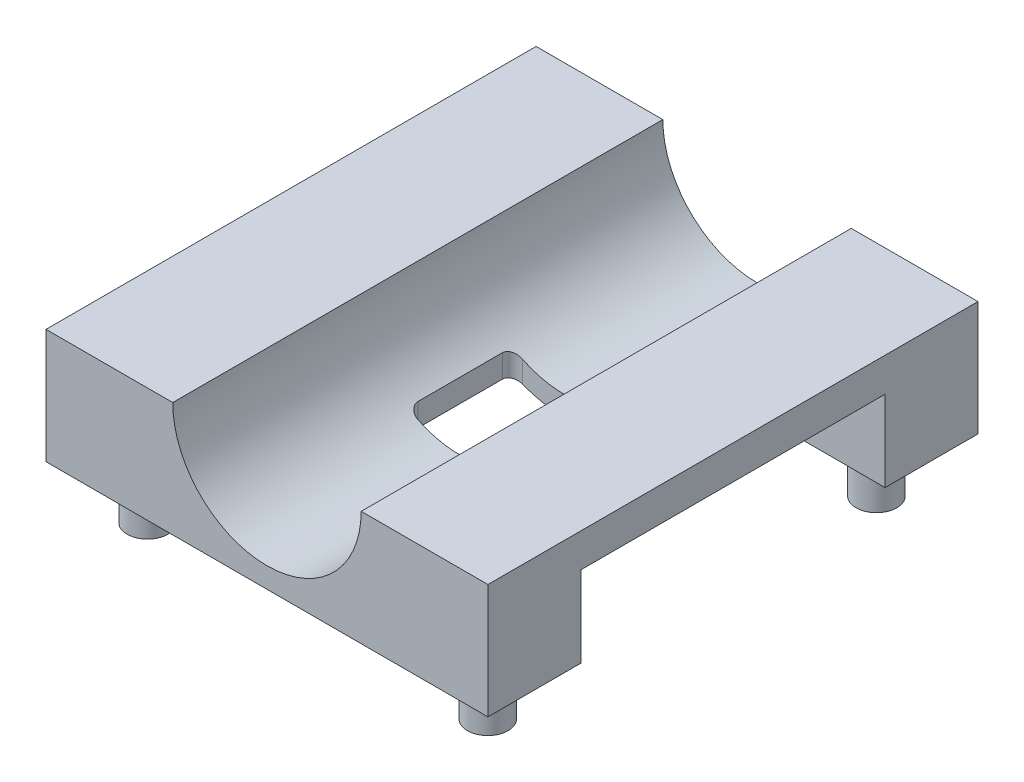
from build123d import *

# Parameters (mm, degrees)
BOSS_EXTRUDE1_DEPTH      = 14.5
BOSS_EXTRUDE1_DEPTH_BACK = 14.5
SKETCH2_R                = 1.205
BOSS_EXTRUDE2_DEPTH      = 3.151836
CUT_EXTRUDE1_START       = 9.93575
CUT_EXTRUDE1_DEPTH       = 10
CUT_EXTRUDE2_DEPTH       = 9
CUT_EXTRUDE2_DEPTH_BACK  = 9


with BuildPart() as part:
    # Sketch1 → Boss-Extrude1 (new body, two sides)
    with BuildSketch(Plane.XY) as boss_extrude1_sk:
        with BuildLine():
            Line((5.575, 9.935749893), (13.075, 9.935749893))
            Line((13.075, 9.935749893), (13.075, 3.151836247))
            Line((13.075, 3.151836247), (-13.075, 3.151836247))
            Line((-13.075, 3.151836247), (-13.075, 9.935749893))
            Line((-13.075, 9.935749893), (-5.575, 9.935749893))
            ThreePointArc((-5.575, 9.935749893), (0, 4.360749893), (5.575, 9.935749893))
        make_face()
    extrude(amount=BOSS_EXTRUDE1_DEPTH)
    extrude(boss_extrude1_sk.sketch, amount=-BOSS_EXTRUDE1_DEPTH_BACK)

    # Sketch2 → Boss-Extrude2 (add)
    with BuildSketch(Plane(origin=(0, 0, 0), x_dir=(1, 0, 0), z_dir=(0, 1, 0))):
        with Locations((10.105, 11.46)):
            Circle(SKETCH2_R)
        with Locations((10.026555832, -11.46)):
            Circle(SKETCH2_R)
        with Locations((-10.105, -11.46)):
            Circle(SKETCH2_R)
        with Locations((-10.105, 11.46)):
            Circle(SKETCH2_R)
    extrude(amount=BOSS_EXTRUDE2_DEPTH)

    # Sketch3 → Cut-Extrude1 (cut)
    with BuildSketch(Plane(origin=(0, 0, 0), x_dir=(1, 0, 0), z_dir=(0, 1, 0)).offset(CUT_EXTRUDE1_START)):
        with BuildLine():
            Line((-2.445097234, 3.077415604), (2.391371835, 3.077415604))
            ThreePointArc((2.391371835, 3.077415604), (2.815635904, 2.901679673), (2.991371835, 2.477415604))
            Line((2.991371835, 2.477415604), (2.991371835, -2.51686965))
            ThreePointArc((2.991371835, -2.51686965), (2.815635904, -2.941133719), (2.391371835, -3.11686965))
            Line((2.391371835, -3.11686965), (-2.445097234, -3.11686965))
            ThreePointArc((-2.445097234, -3.11686965), (-2.869361302, -2.941133719), (-3.045097234, -2.51686965))
            Line((-3.045097234, -2.51686965), (-3.045097234, 2.477415604))
            ThreePointArc((-3.045097234, 2.477415604), (-2.869361302, 2.901679673), (-2.445097234, 3.077415604))
        make_face()
    extrude(amount=-CUT_EXTRUDE1_DEPTH, mode=Mode.SUBTRACT)

    # Sketch5 → Cut-Extrude2 (cut, two sides)
    with BuildSketch(Plane.XY) as cut_extrude2_sk:
        with BuildLine():
            Line((-6.450228257, 7.935749893), (-13.075, 7.935749893))
            Line((-13.075, 7.935749893), (-13.075, 3.151836247))
            Line((-13.075, 3.151836247), (13.075, 3.151836247))
            Line((13.075, 3.151836247), (13.075, 7.935749893))
            Line((13.075, 7.935749893), (6.450228257, 7.935749893))
            ThreePointArc((6.450228257, 7.935749893), (0, 3.182569563), (-6.450228257, 7.935749893))
        make_face()
    extrude(amount=CUT_EXTRUDE2_DEPTH, mode=Mode.SUBTRACT)
    extrude(cut_extrude2_sk.sketch, amount=-CUT_EXTRUDE2_DEPTH_BACK, mode=Mode.SUBTRACT)


solid = part.part
